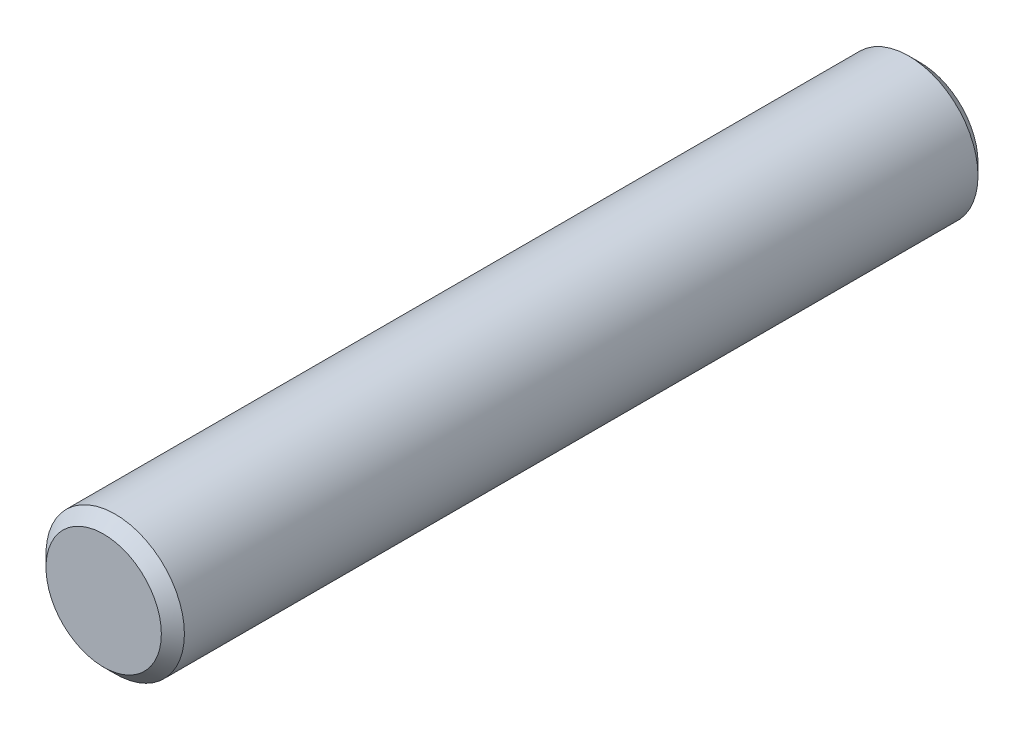
from build123d import *

# Parameters (mm, degrees)
SKETCH1_R           = 4.7625
BOSS_EXTRUDE1_DEPTH = 56.2
CHAMFER1_SIZE       = 0.79375


with BuildPart() as part:
    # Sketch1 → Boss-Extrude1 (new body)
    with BuildSketch(Plane.XY):
        Circle(SKETCH1_R)
    extrude(amount=BOSS_EXTRUDE1_DEPTH)

    # Chamfer1
    chamfer1_edges = [part.edges().sort_by_distance(p)[0] for p in [
        (-4.7625, 0, 0),
        (-4.7625, 0, 56.2),
    ]]
    chamfer(chamfer1_edges, length=CHAMFER1_SIZE)


solid = part.part
